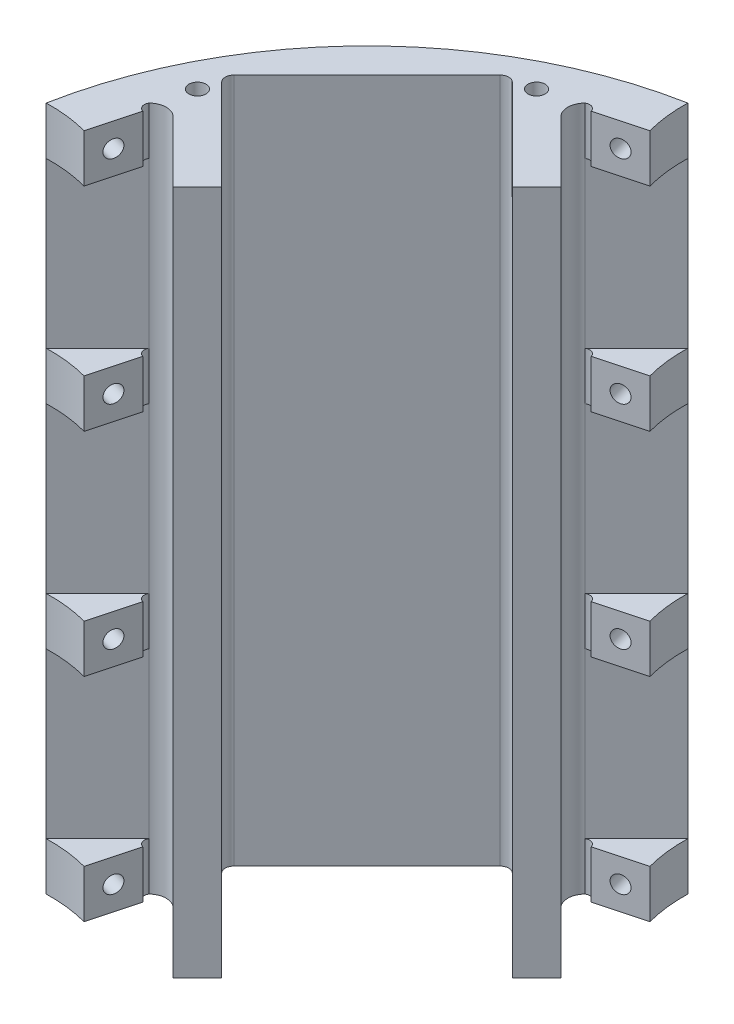
from build123d import *

# Parameters (mm, degrees)
CRADLE_DEPTH            = 254
SKETCH1_R               = 3.175
CUT_EXTRUDE1_DEPTH      = 12.7
EIGTH_INCH_FILLETS_R    = 3.175
QUARTER_INCH_FILLETS_R  = 6.35
SKETCH4_R               = 1.27
WIRE_HOLES_DEPTH        = 331.107912003
BOSS_EXTRUDE1_DEPTH     = 17.78
SKETCH6_R               = 3.175
CUT_EXTRUDE2_DEPTH      = 297.567916911
LPATTERN1_COUNT         = 4
LPATTERN1_PITCH         = 78.74
MIRROR2_COPY_1_DEPTH    = 17.78
MIRROR2_COPY_2_DEPTH    = 17.78
MIRROR2_COPY_3_DEPTH    = 17.78
MIRROR2_COPY_4_SKETCH_R = 3.175
MIRROR2_COPY_4_DEPTH    = 297.567916911
MIRROR2_COPY_5_SKETCH_R = 3.175
MIRROR2_COPY_5_DEPTH    = 297.567916911
MIRROR2_COPY_6_SKETCH_R = 3.175
MIRROR2_COPY_6_DEPTH    = 297.567916911


with BuildPart() as part:
    # Base → Cradle (new body)
    with BuildSketch(Plane(origin=(0, 0, 0), x_dir=(1, 0, 0), z_dir=(0, 1, 0))):
        with BuildLine():
            Line((-27.68192265, 146.634960986), (-51.237417334, 123.079466302))
            Line((-51.237417334, 123.079466302), (-24.296648971, 96.138697939))
            Line((-24.296648971, 96.138697939), (-33.276905092, 87.158441818))
            Line((-33.276905092, 87.158441818), (-69.197929576, 123.079466302))
            Line((-69.197929576, 123.079466302), (-123.079466302, 69.197929576))
            Line((-123.079466302, 69.197929576), (-87.158441818, 33.276905092))
            Line((-87.158441818, 33.276905092), (-96.138697939, 24.296648971))
            Line((-96.138697939, 24.296648971), (-123.079466302, 51.237417334))
            Line((-123.079466302, 51.237417334), (-146.634960986, 27.68192265))
            ThreePointArc((-146.634960986, 27.68192265), (-105.518009423, 105.518009423), (-27.68192265, 146.634960986))
        make_face()
    extrude(amount=CRADLE_DEPTH)

    # Sketch1 → Cut-Extrude1 (cut)
    with BuildSketch(Plane(origin=(0, 254, 0), x_dir=(1, 0, 0), z_dir=(0, 1, 0))):
        with Locations((-60.217673455, 123.079466302)):
            Circle(SKETCH1_R)
        with Locations((-123.079466302, 60.217673455)):
            Circle(SKETCH1_R)
    cut_extrude1 = extrude(amount=-CUT_EXTRUDE1_DEPTH, mode=Mode.SUBTRACT)

    # Mirror1: Cut-Extrude1 across plane
    add(cut_extrude1.mirror(Plane.ZX.offset(127)), mode=Mode.SUBTRACT)

    # Eigth Inch Fillets
    eigth_inch_fillets_edges = [part.edges().sort_by_distance(p)[0] for p in [
        (-123.079466302, 127, -69.197929576),
        (-69.197929576, 127, -123.079466302),
    ]]
    fillet(eigth_inch_fillets_edges, radius=EIGTH_INCH_FILLETS_R)

    # Quarter Inch Fillets
    quarter_inch_fillets_edges = [part.edges().sort_by_distance(p)[0] for p in [
        (-123.079466302, 127, -51.237417334),
        (-51.237417334, 127, -123.079466302),
    ]]
    fillet(quarter_inch_fillets_edges, radius=QUARTER_INCH_FILLETS_R)

    # Sketch4 → Wire Holes (cut, through all)
    with BuildSketch(Plane(origin=(26.940768363, 0, -26.940768363), x_dir=(0.7071067811865476, 0, 0.7071067811865476), z_dir=(-0.7071067811865476, 0, 0.7071067811865476))):
        with Locations((-108.973150495, 127)):
            Circle(SKETCH4_R)
        with Locations((-108.973150495, 101.6)):
            Circle(SKETCH4_R)
        with Locations((-108.973150495, 76.2)):
            Circle(SKETCH4_R)
        with Locations((-108.973150495, 50.8)):
            Circle(SKETCH4_R)
        with Locations((-108.973150495, 25.4)):
            Circle(SKETCH4_R)
        with Locations((-108.973150495, 152.4)):
            Circle(SKETCH4_R)
        with Locations((-108.973150495, 177.8)):
            Circle(SKETCH4_R)
        with Locations((-108.973150495, 203.2)):
            Circle(SKETCH4_R)
        with Locations((-96.273150495, 25.4)):
            Circle(SKETCH4_R)
        with Locations((-96.273150495, 50.8)):
            Circle(SKETCH4_R)
        with Locations((-96.273150495, 76.2)):
            Circle(SKETCH4_R)
        with Locations((-96.273150495, 101.6)):
            Circle(SKETCH4_R)
        with Locations((-96.273150495, 127)):
            Circle(SKETCH4_R)
        with Locations((-96.273150495, 152.4)):
            Circle(SKETCH4_R)
        with Locations((-96.273150495, 177.8)):
            Circle(SKETCH4_R)
        with Locations((-96.273150495, 203.2)):
            Circle(SKETCH4_R)
        with Locations((-96.273150495, 228.6)):
            Circle(SKETCH4_R)
        with Locations((-108.973150495, 228.6)):
            Circle(SKETCH4_R)
    extrude(amount=-WIRE_HOLES_DEPTH, mode=Mode.SUBTRACT)

    # Sketch5 → Boss-Extrude1 (add)
    with BuildSketch(Plane(origin=(0, 0, 0), x_dir=(1, 0, 0), z_dir=(0, 1, 0))):
        with BuildLine():
            Line((-42.997881452, 126.121955812), (-25.82372026, 130.723758434))
            ThreePointArc((-25.82372026, 130.723758434), (-27.332775578, 138.611629309), (-27.68192265, 146.634960986))
            Line((-27.68192265, 146.634960986), (-46.747289273, 127.569594363))
            ThreePointArc((-46.747289273, 127.569594363), (-44.504667487, 127.798688479), (-42.997881452, 126.121955812))
        make_face()
    boss_extrude1 = extrude(amount=BOSS_EXTRUDE1_DEPTH)

    # Sketch6 → Cut-Extrude2 (cut, through all)
    with BuildSketch(Plane(origin=(-34.410800856, 0, -128.422857123), x_dir=(0.9659258262890698, 0, -0.2588190451025154), z_dir=(0.2588190451025154, 0, 0.9659258262890698))):
        with Locations((0, 8.89)):
            Circle(SKETCH6_R)
    cut_extrude2 = extrude(amount=-CUT_EXTRUDE2_DEPTH, mode=Mode.SUBTRACT)

    # LPattern1: Boss-Extrude1, Cut-Extrude2 ×4
    with Locations(*[(0, i * LPATTERN1_PITCH, 0) for i in range(1, LPATTERN1_COUNT)]):
        add(boss_extrude1)
        add(cut_extrude2, mode=Mode.SUBTRACT)

    # Mirror2: Boss-Extrude1, Cut-Extrude2 across plane
    add(boss_extrude1.mirror(Plane(origin=(0, 0, 0), x_dir=(0.7071067811865477, 0, 0.7071067811865474), z_dir=(-0.7071067811865474, 0, 0.7071067811865477))))
    add(cut_extrude2.mirror(Plane(origin=(0, 0, 0), x_dir=(0.7071067811865477, 0, 0.7071067811865474), z_dir=(-0.7071067811865474, 0, 0.7071067811865477))), mode=Mode.SUBTRACT)

    # Mirror2 copy 1 sketch → Mirror2 copy 1 (add)
    with BuildSketch(Plane.ZX.offset(78.74)):
        with BuildLine():
            Line((-42.997881452, -126.121955812), (-25.82372026, -130.723758434))
            ThreePointArc((-25.82372026, -130.723758434), (-27.332775578, -138.611629309), (-27.68192265, -146.634960986))
            Line((-27.68192265, -146.634960986), (-46.747289273, -127.569594363))
            ThreePointArc((-46.747289273, -127.569594363), (-44.504667487, -127.798688479), (-42.997881452, -126.121955812))
        make_face()
    extrude(amount=MIRROR2_COPY_1_DEPTH)

    # Mirror2 copy 2 sketch → Mirror2 copy 2 (add)
    with BuildSketch(Plane.ZX.offset(157.48)):
        with BuildLine():
            Line((-42.997881452, -126.121955812), (-25.82372026, -130.723758434))
            ThreePointArc((-25.82372026, -130.723758434), (-27.332775578, -138.611629309), (-27.68192265, -146.634960986))
            Line((-27.68192265, -146.634960986), (-46.747289273, -127.569594363))
            ThreePointArc((-46.747289273, -127.569594363), (-44.504667487, -127.798688479), (-42.997881452, -126.121955812))
        make_face()
    extrude(amount=MIRROR2_COPY_2_DEPTH)

    # Mirror2 copy 3 sketch → Mirror2 copy 3 (add)
    with BuildSketch(Plane.ZX.offset(236.22)):
        with BuildLine():
            Line((-42.997881452, -126.121955812), (-25.82372026, -130.723758434))
            ThreePointArc((-25.82372026, -130.723758434), (-27.332775578, -138.611629309), (-27.68192265, -146.634960986))
            Line((-27.68192265, -146.634960986), (-46.747289273, -127.569594363))
            ThreePointArc((-46.747289273, -127.569594363), (-44.504667487, -127.798688479), (-42.997881452, -126.121955812))
        make_face()
    extrude(amount=MIRROR2_COPY_3_DEPTH)

    # Mirror2 copy 4 sketch → Mirror2 copy 4 (cut, through all)
    with BuildSketch(Plane(origin=(-128.422857123, 78.74, -34.410800856), x_dir=(-0.25881904510251497, 0, 0.9659258262890699), z_dir=(0.9659258262890699, 0, 0.25881904510251497))):
        with Locations((0, -8.89)):
            Circle(MIRROR2_COPY_4_SKETCH_R)
    extrude(amount=-MIRROR2_COPY_4_DEPTH, mode=Mode.SUBTRACT)

    # Mirror2 copy 5 sketch → Mirror2 copy 5 (cut, through all)
    with BuildSketch(Plane(origin=(-128.422857123, 157.48, -34.410800856), x_dir=(-0.25881904510251497, 0, 0.9659258262890699), z_dir=(0.9659258262890699, 0, 0.25881904510251497))):
        with Locations((0, -8.89)):
            Circle(MIRROR2_COPY_5_SKETCH_R)
    extrude(amount=-MIRROR2_COPY_5_DEPTH, mode=Mode.SUBTRACT)

    # Mirror2 copy 6 sketch → Mirror2 copy 6 (cut, through all)
    with BuildSketch(Plane(origin=(-128.422857123, 236.22, -34.410800856), x_dir=(-0.25881904510251497, 0, 0.9659258262890699), z_dir=(0.9659258262890699, 0, 0.25881904510251497))):
        with Locations((0, -8.89)):
            Circle(MIRROR2_COPY_6_SKETCH_R)
    extrude(amount=-MIRROR2_COPY_6_DEPTH, mode=Mode.SUBTRACT)


solid = part.part
